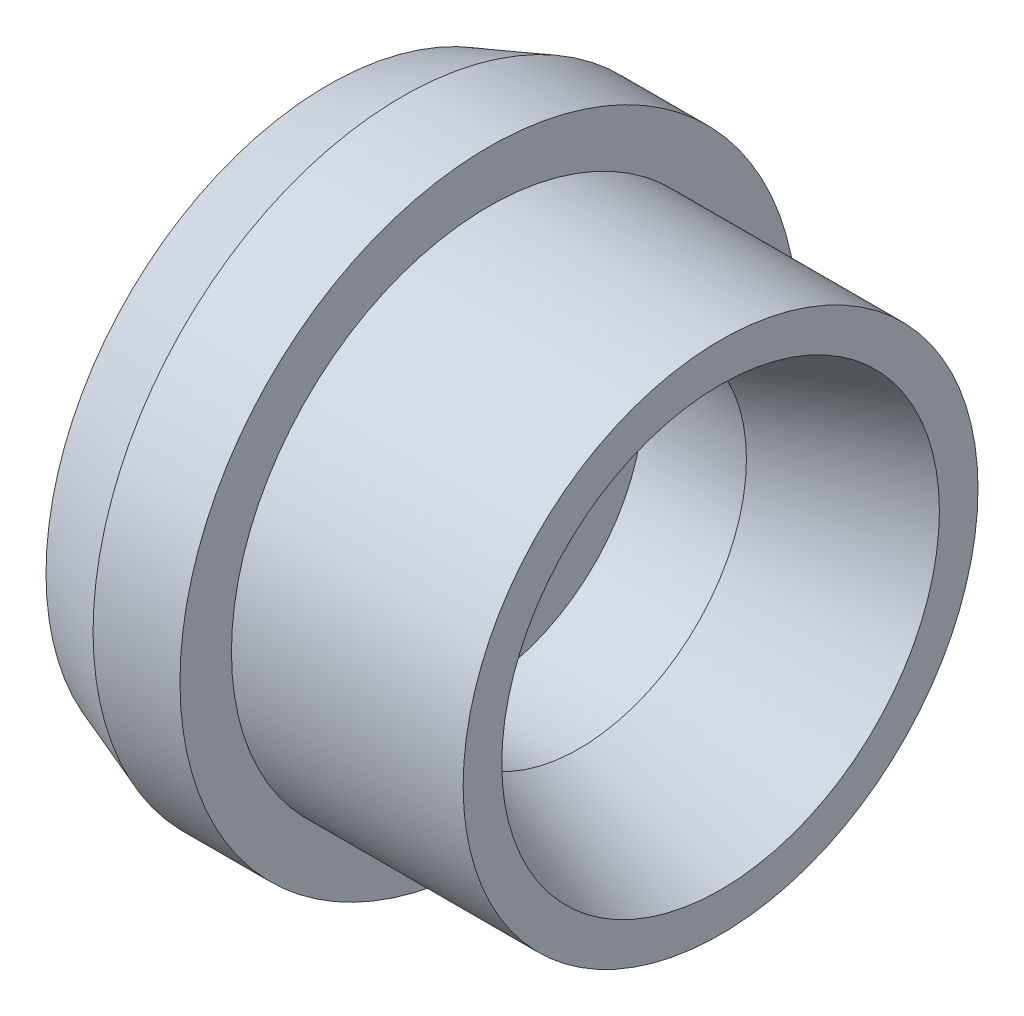
from build123d import *


with BuildPart() as part:
    # Sketch1 → Revolve1 (revolve)
    with BuildSketch(Plane.XY):
        Polygon((0, 0), (0, 5.564421473), (1.4605, 6.096), (3.175, 6.096), (3.175, 5.08), (7.747, 5.08), (7.747, 4.318), (4.955562942, 3.302), (2.921, 3.302), (2.921, 0), align=None)
    revolve(axis=Axis((2.921, 0, 0), (-1, 0, 0)))


solid = part.part
